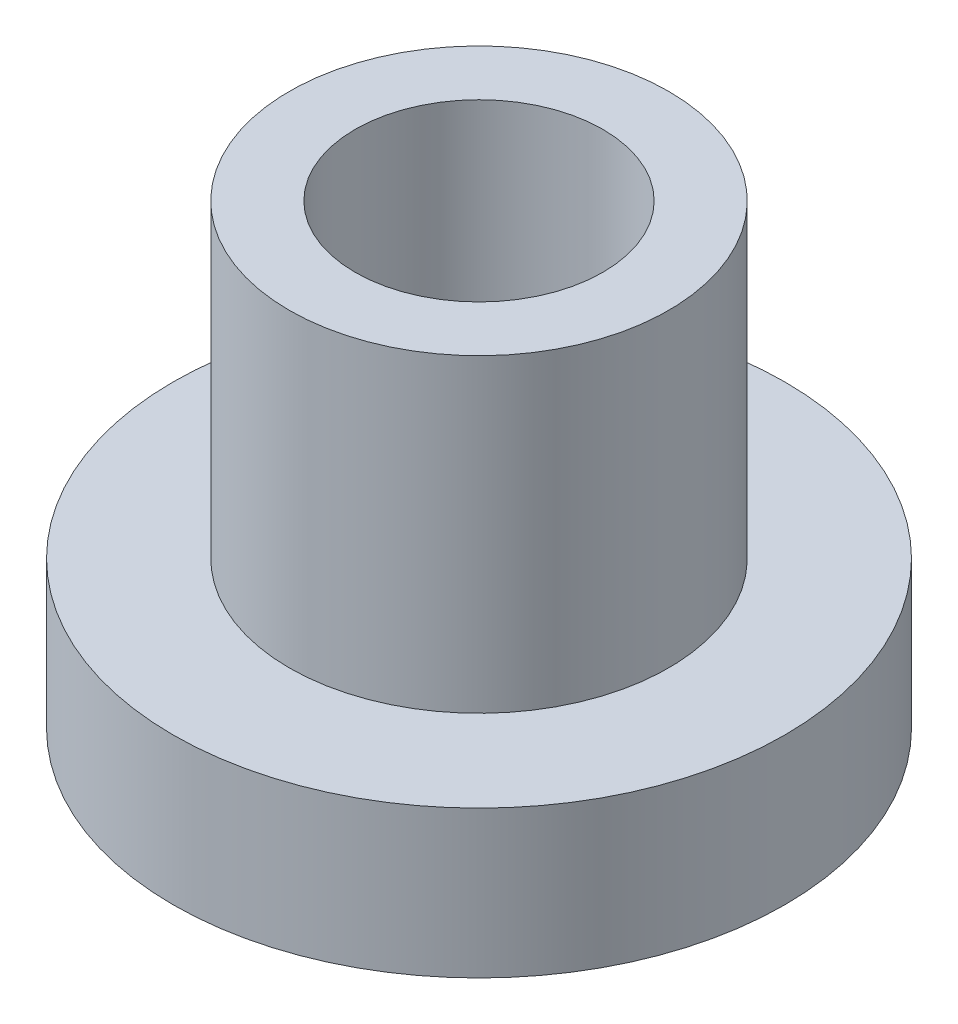
from build123d import *

# Parameters (mm, degrees)
SKETCH1_R           = 3.95
SKETCH1_R_2         = 1.6
BOSS_EXTRUDE1_DEPTH = 1.9
SKETCH2_R           = 2.45
SKETCH2_R_2         = 1.6
BOSS_EXTRUDE2_DEPTH = 4


with BuildPart() as part:
    # Sketch1 → Boss-Extrude1 (new body)
    with BuildSketch(Plane(origin=(0, 0, 0), x_dir=(1, 0, 0), z_dir=(0, 1, 0))):
        Circle(SKETCH1_R)
        Circle(SKETCH1_R_2, mode=Mode.SUBTRACT)
    extrude(amount=BOSS_EXTRUDE1_DEPTH)

    # Sketch2 → Boss-Extrude2 (add)
    with BuildSketch(Plane(origin=(0, 1.9, 0), x_dir=(1, 0, 0), z_dir=(0, 1, 0))):
        Circle(SKETCH2_R)
        Circle(SKETCH2_R_2, mode=Mode.SUBTRACT)
    extrude(amount=BOSS_EXTRUDE2_DEPTH)


solid = part.part
